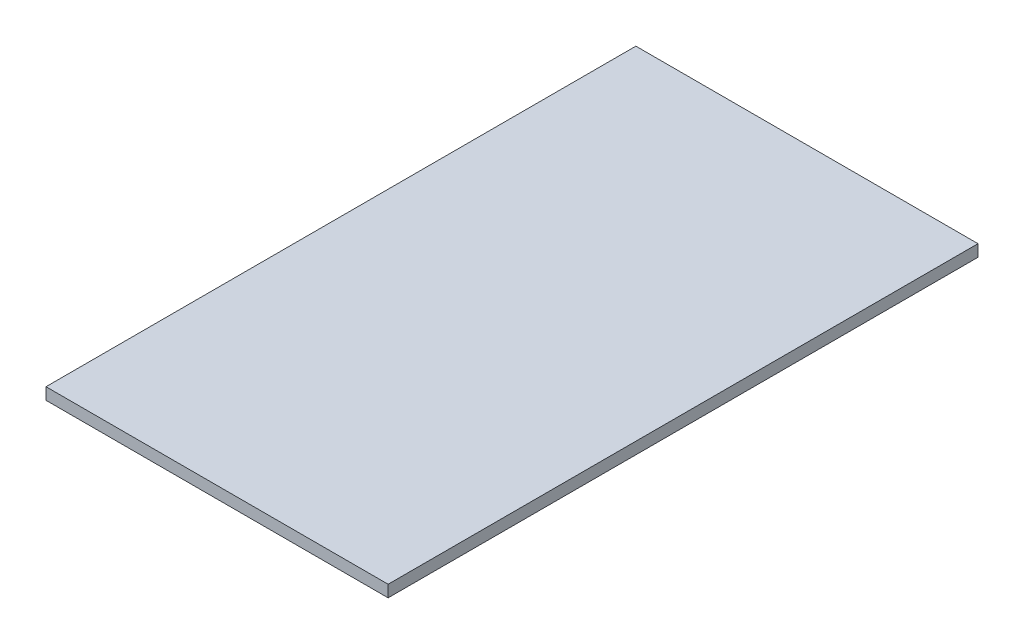
from build123d import *

# Parameters (mm, degrees)
SKETCH1_W           = 184.15
SKETCH1_H           = 317.5
BOSS_EXTRUDE1_DEPTH = 6.35


with BuildPart() as part:
    # Sketch1 → Boss-Extrude1 (new body)
    with BuildSketch(Plane(origin=(0, 0, 0), x_dir=(1, 0, 0), z_dir=(0, 1, 0))):
        with Locations((92.075, 158.75)):
            Rectangle(SKETCH1_W, SKETCH1_H)
    extrude(amount=BOSS_EXTRUDE1_DEPTH)


solid = part.part
